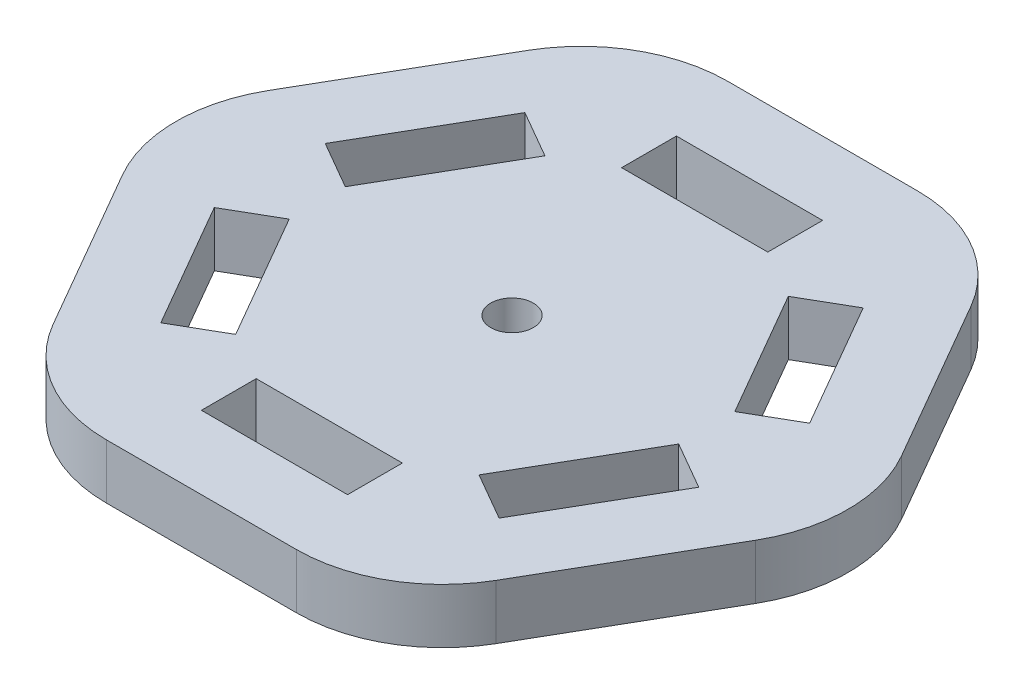
from build123d import *

# Parameters (mm, degrees)
SKETCH_1_R      = 1.75
SKETCH_1_W      = 12
SKETCH_1_H      = 4.5
EXTRUDE_1_DEPTH = 4.5
FILLET_1_R      = 12


with BuildPart() as part:
    # 草图1 → 凸台-拉伸1 (new body)
    with BuildSketch(Plane(origin=(0, 0, 0), x_dir=(1, 0, 0), z_dir=(0, 1, 0))):
        Polygon((29.444863729, 0), (14.722431864, 25.5), (-14.722431864, 25.5), (-29.444863729, 0), (-14.722431864, -25.5), (14.722431864, -25.5), align=None)
        Circle(SKETCH_1_R, mode=Mode.SUBTRACT)
        Polygon((13.887495374, 14.946152423), (9.990381057, 12.696152423), (15.990381057, 2.303847577), (19.887495374, 4.553847577), align=None, mode=Mode.SUBTRACT)
        with Locations((0, 17.25)):
            Rectangle(SKETCH_1_W, SKETCH_1_H, mode=Mode.SUBTRACT)
        Polygon((19.887495374, -4.553847577), (15.990381057, -2.303847577), (9.990381057, -12.696152423), (13.887495374, -14.946152423), align=None, mode=Mode.SUBTRACT)
        with Locations((0, -17.25)):
            Rectangle(SKETCH_1_W, SKETCH_1_H, mode=Mode.SUBTRACT)
        Polygon((-13.887495374, -14.946152423), (-9.990381057, -12.696152423), (-15.990381057, -2.303847577), (-19.887495374, -4.553847577), align=None, mode=Mode.SUBTRACT)
        Polygon((-19.887495374, 4.553847577), (-15.990381057, 2.303847577), (-9.990381057, 12.696152423), (-13.887495374, 14.946152423), align=None, mode=Mode.SUBTRACT)
    extrude(amount=EXTRUDE_1_DEPTH)

    # 圆角1
    fillet_1_edges = [part.edges().sort_by_distance(p)[0] for p in [
        (14.722431864, 2.25, 25.5),
        (-14.722431864, 2.25, 25.5),
        (-29.444863729, 2.25, 0),
        (-14.722431864, 2.25, -25.5),
        (14.722431864, 2.25, -25.5),
        (29.444863729, 2.25, 0),
    ]]
    fillet(fillet_1_edges, radius=FILLET_1_R)


solid = part.part
